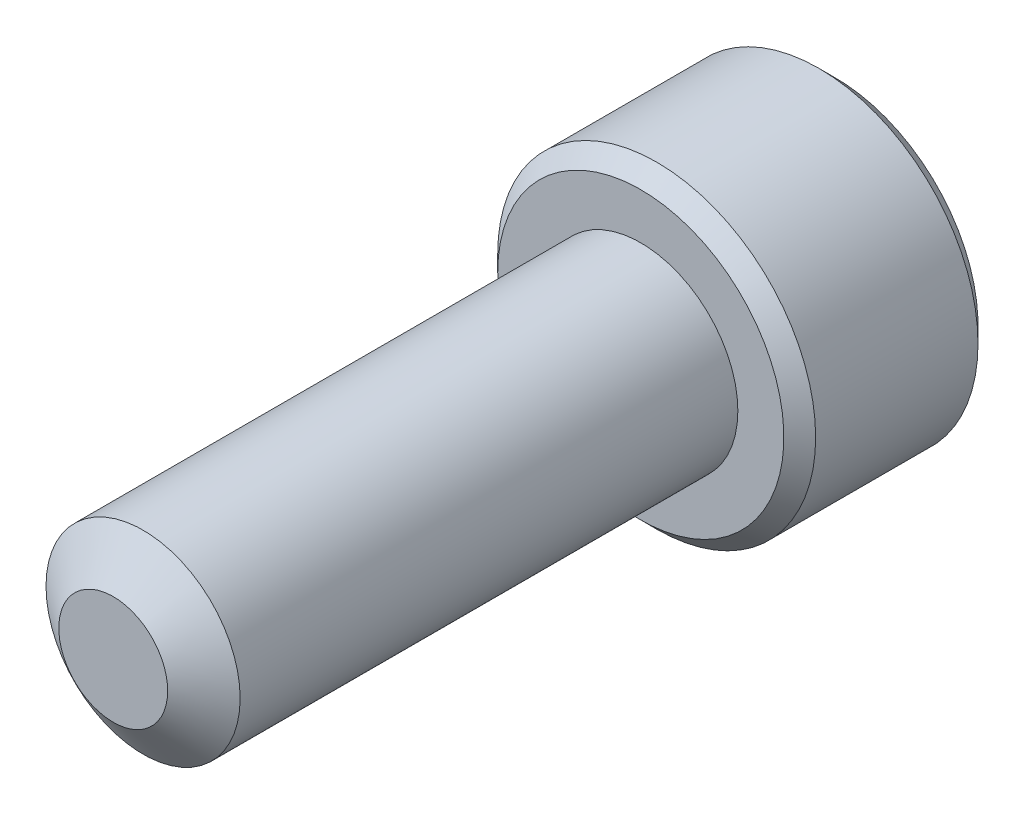
from build123d import *

# Parameters (mm, degrees)
SKETCH1_R          = 1.7526
EXTRUDE1_DEPTH     = 9.525
SKETCH6_R          = 2.8702
EXTRUDE2_DEPTH     = 3.5052
CUT_EXTRUDE1_DEPTH = 2.08359375
CHAMFER1_SIZE      = 0.28702


with BuildPart() as part:
    # Sketch1 → Extrude1 (new body)
    with BuildSketch(Plane.XY):
        Circle(SKETCH1_R)
    extrude(amount=-EXTRUDE1_DEPTH)

    # Sketch4 → Cut-Revolve1 (revolve, cut)
    with BuildSketch(Plane(origin=(0, 0, 0), x_dir=(0, 0, -1), z_dir=(1, 0, 0))):
        Polygon((0.538848736, 1.7526), (0, 0.983044252), (0, 1.7526), align=None)
    revolve(axis=Axis((0, 0, 0), (0, 0, -1)), mode=Mode.SUBTRACT)

    # Sketch6 → Extrude2 (add)
    with BuildSketch(Plane(origin=(0, 0, -9.525), x_dir=(-1, 0, 0), z_dir=(0, 0, -1))):
        Circle(SKETCH6_R)
    extrude(amount=EXTRUDE2_DEPTH)

    # Sketch7 → Cut-Extrude1 (cut)
    with BuildSketch(Plane(origin=(0, 0, -13.0302), x_dir=(-1, 0, 0), z_dir=(0, 0, -1))):
        Polygon((0, 1.603951217), (-1.3890625, 0.801975608), (-1.3890625, -0.801975608), (0, -1.603951217), (1.3890625, -0.801975608), (1.3890625, 0.801975608), align=None)
    extrude(amount=-CUT_EXTRUDE1_DEPTH, mode=Mode.SUBTRACT)

    # Cut-Extrude2 cone 1 section (through the dimple's axis) → Cut-Extrude2 (revolve, cut)
    with BuildSketch(Plane(origin=(0, 0, -13.0302), x_dir=(0, 1, 0), z_dir=(1, 0, 0))):
        Polygon((0, 0), (1.603951217, 0), (0, 1.603951217), align=None)
    revolve(axis=Axis((0, 0, -13.0302), (0, 0, 1)), mode=Mode.SUBTRACT)

    # Chamfer1
    chamfer1_edges = [part.edges().sort_by_distance(p)[0] for p in [
        (2.8702, 0, -13.0302),
        (2.8702, 0, -9.525),
    ]]
    chamfer(chamfer1_edges, length=CHAMFER1_SIZE)


solid = part.part
